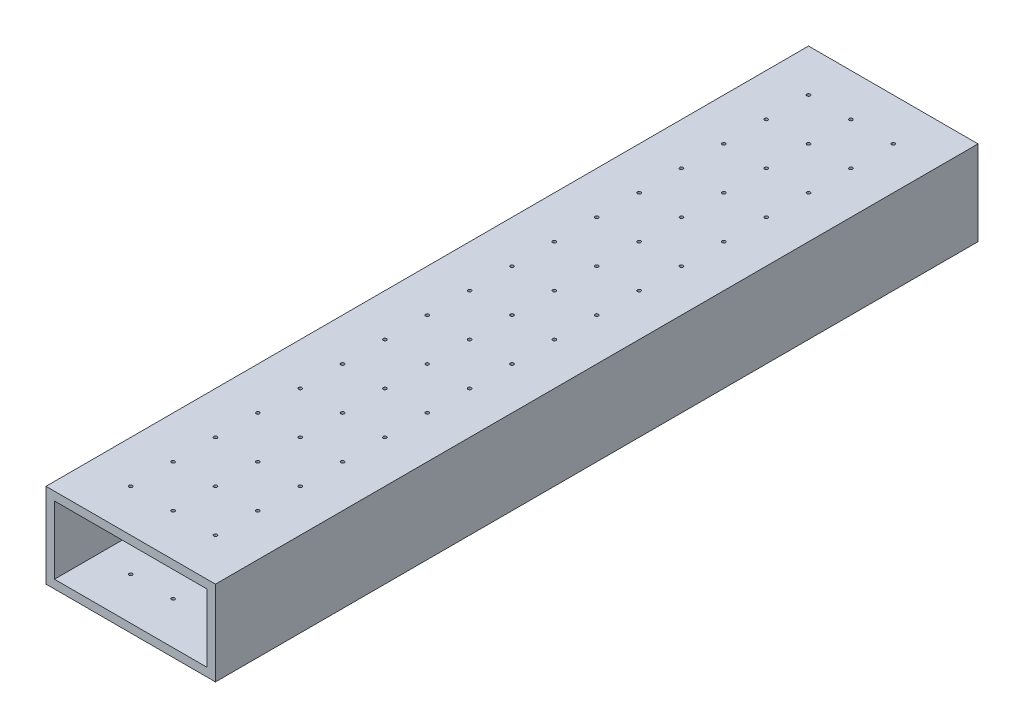
from build123d import *

# Parameters (mm, degrees)
SKETCH1_W               = 50.8
SKETCH1_H               = 25.4
SKETCH1_W_2             = 45.72
SKETCH1_H_2             = 20.32
BOSS_EXTRUDE1_DEPTH     = 228.6
SKETCH2_R               = 0.5
CUT_EXTRUDE1_DEPTH      = 1
CUT_EXTRUDE1_DEPTH_BACK = 26.4


with BuildPart() as part:
    # Sketch1 → Boss-Extrude1 (new body)
    with BuildSketch(Plane.XY):
        with Locations((0.958397508, -0.419684268)):
            Rectangle(SKETCH1_W, SKETCH1_H)
        with Locations((0.958397508, -0.419684268)):
            Rectangle(SKETCH1_W_2, SKETCH1_H_2, mode=Mode.SUBTRACT)
    extrude(amount=BOSS_EXTRUDE1_DEPTH)

    # Sketch2 → Cut-Extrude1 (cut, two sides)
    with BuildSketch(Plane(origin=(0, 12.280315732, 0), x_dir=(1, 0, 0), z_dir=(0, 1, 0))) as cut_extrude1_sk:
        with Locations((-11.741602492, -215.9)):
            Circle(SKETCH2_R)
        with Locations((0.958397508, -215.9)):
            Circle(SKETCH2_R)
        with Locations((13.658397508, -215.9)):
            Circle(SKETCH2_R)
        with Locations((0.958397508, -203.2)):
            Circle(SKETCH2_R)
        with Locations((13.658397508, -203.2)):
            Circle(SKETCH2_R)
        with Locations((0.958397508, -190.5)):
            Circle(SKETCH2_R)
        with Locations((13.658397508, -190.5)):
            Circle(SKETCH2_R)
        with Locations((0.958397508, -177.8)):
            Circle(SKETCH2_R)
        with Locations((13.658397508, -177.8)):
            Circle(SKETCH2_R)
        with Locations((0.958397508, -165.1)):
            Circle(SKETCH2_R)
        with Locations((13.658397508, -165.1)):
            Circle(SKETCH2_R)
        with Locations((0.958397508, -152.4)):
            Circle(SKETCH2_R)
        with Locations((13.658397508, -152.4)):
            Circle(SKETCH2_R)
        with Locations((0.958397508, -139.7)):
            Circle(SKETCH2_R)
        with Locations((13.658397508, -139.7)):
            Circle(SKETCH2_R)
        with Locations((0.958397508, -127)):
            Circle(SKETCH2_R)
        with Locations((13.658397508, -127)):
            Circle(SKETCH2_R)
        with Locations((0.958397508, -114.3)):
            Circle(SKETCH2_R)
        with Locations((13.658397508, -114.3)):
            Circle(SKETCH2_R)
        with Locations((0.958397508, -101.6)):
            Circle(SKETCH2_R)
        with Locations((13.658397508, -101.6)):
            Circle(SKETCH2_R)
        with Locations((0.958397508, -88.9)):
            Circle(SKETCH2_R)
        with Locations((13.658397508, -88.9)):
            Circle(SKETCH2_R)
        with Locations((0.958397508, -76.2)):
            Circle(SKETCH2_R)
        with Locations((13.658397508, -76.2)):
            Circle(SKETCH2_R)
        with Locations((0.958397508, -63.5)):
            Circle(SKETCH2_R)
        with Locations((13.658397508, -63.5)):
            Circle(SKETCH2_R)
        with Locations((0.958397508, -50.8)):
            Circle(SKETCH2_R)
        with Locations((13.658397508, -50.8)):
            Circle(SKETCH2_R)
        with Locations((0.958397508, -38.1)):
            Circle(SKETCH2_R)
        with Locations((13.658397508, -38.1)):
            Circle(SKETCH2_R)
        with Locations((0.958397508, -25.4)):
            Circle(SKETCH2_R)
        with Locations((13.658397508, -25.4)):
            Circle(SKETCH2_R)
        with Locations((0.958397508, -12.7)):
            Circle(SKETCH2_R)
        with Locations((13.658397508, -12.7)):
            Circle(SKETCH2_R)
        with Locations((-11.741602492, -203.2)):
            Circle(SKETCH2_R)
        with Locations((-11.741602492, -190.5)):
            Circle(SKETCH2_R)
        with Locations((-11.741602492, -177.8)):
            Circle(SKETCH2_R)
        with Locations((-11.741602492, -165.1)):
            Circle(SKETCH2_R)
        with Locations((-11.741602492, -152.4)):
            Circle(SKETCH2_R)
        with Locations((-11.741602492, -139.7)):
            Circle(SKETCH2_R)
        with Locations((-11.741602492, -127)):
            Circle(SKETCH2_R)
        with Locations((-11.741602492, -114.3)):
            Circle(SKETCH2_R)
        with Locations((-11.741602492, -101.6)):
            Circle(SKETCH2_R)
        with Locations((-11.741602492, -88.9)):
            Circle(SKETCH2_R)
        with Locations((-11.741602492, -76.2)):
            Circle(SKETCH2_R)
        with Locations((-11.741602492, -63.5)):
            Circle(SKETCH2_R)
        with Locations((-11.741602492, -50.8)):
            Circle(SKETCH2_R)
        with Locations((-11.741602492, -38.1)):
            Circle(SKETCH2_R)
        with Locations((-11.741602492, -25.4)):
            Circle(SKETCH2_R)
        with Locations((-11.741602492, -12.7)):
            Circle(SKETCH2_R)
    extrude(amount=CUT_EXTRUDE1_DEPTH, mode=Mode.SUBTRACT)
    extrude(cut_extrude1_sk.sketch, amount=-CUT_EXTRUDE1_DEPTH_BACK, mode=Mode.SUBTRACT)


solid = part.part
